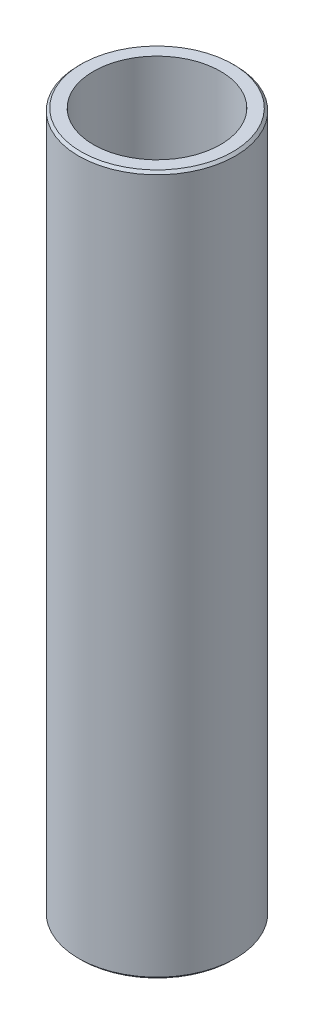
from build123d import *

# Parameters (mm, degrees)
SKETCH1_R           = 7.94
SKETCH1_R_2         = 6.44
BOSS_EXTRUDE1_DEPTH = 70.91
CHAMFER1_SIZE       = 0.25


with BuildPart() as part:
    # Sketch1 → Boss-Extrude1 (new body)
    with BuildSketch(Plane(origin=(0, 0, 0), x_dir=(1, 0, 0), z_dir=(0, 1, 0))):
        Circle(SKETCH1_R)
        Circle(SKETCH1_R_2, mode=Mode.SUBTRACT)
    extrude(amount=BOSS_EXTRUDE1_DEPTH)

    # Chamfer1
    chamfer1_edges = [part.edges().sort_by_distance(p)[0] for p in [
        (-7.94, 0, 0),
        (-7.94, 70.91, 0),
    ]]
    chamfer(chamfer1_edges, length=CHAMFER1_SIZE)


solid = part.part
